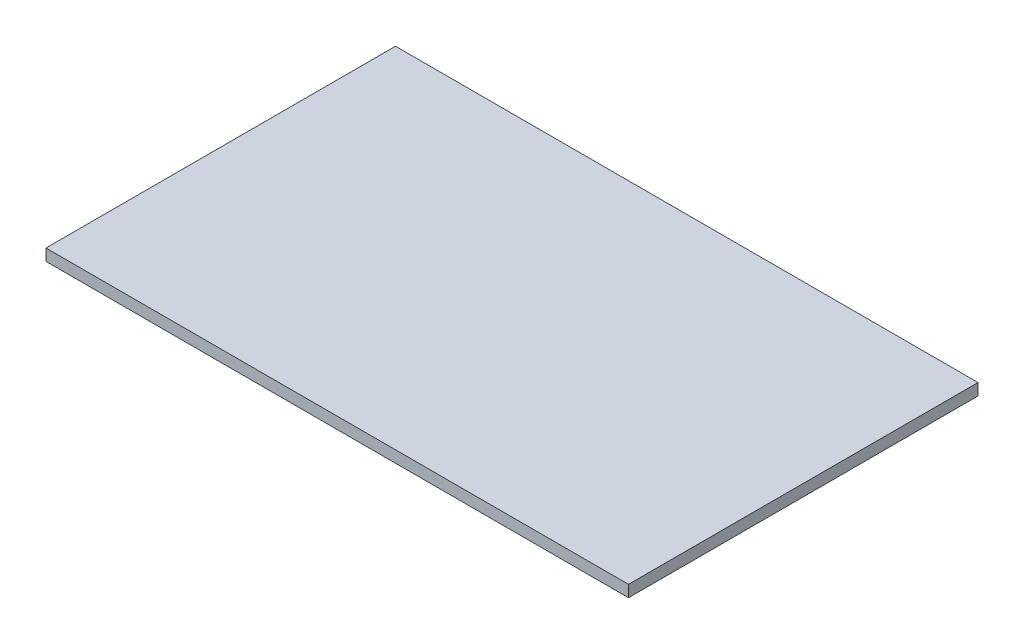
from build123d import *

# Parameters (mm, degrees)
BOSS_EXTRUDE1_DEPTH = 2
SKETCH4_W           = 100
SKETCH4_H           = 60
BOSS_EXTRUDE3_DEPTH = 2


with BuildPart() as part:
    # Sketch2 → Boss-Extrude1 (new body)
    with BuildSketch(Plane(origin=(0, 0, 0), x_dir=(1, 0, 0), z_dir=(0, 1, 0))):
        with BuildLine():
            Line((-29.5, 15), (29.5, 15))
            ThreePointArc((29.5, 15), (31.621320344, 14.121320344), (32.5, 12))
            Line((32.5, 12), (32.5, -12))
            ThreePointArc((32.5, -12), (31.621320344, -14.121320344), (29.5, -15))
            Line((29.5, -15), (-29.5, -15))
            ThreePointArc((-29.5, -15), (-31.621320344, -14.121320344), (-32.5, -12))
            Line((-32.5, -12), (-32.5, 12))
            ThreePointArc((-32.5, 12), (-31.621320344, 14.121320344), (-29.5, 15))
        make_face()
    extrude(amount=BOSS_EXTRUDE1_DEPTH)

    # Sketch4 → Boss-Extrude3 (add)
    with BuildSketch(Plane(origin=(0, 0, 0), x_dir=(1, 0, 0), z_dir=(0, 1, 0))):
        Rectangle(SKETCH4_W, SKETCH4_H)
    extrude(amount=BOSS_EXTRUDE3_DEPTH)


solid = part.part
